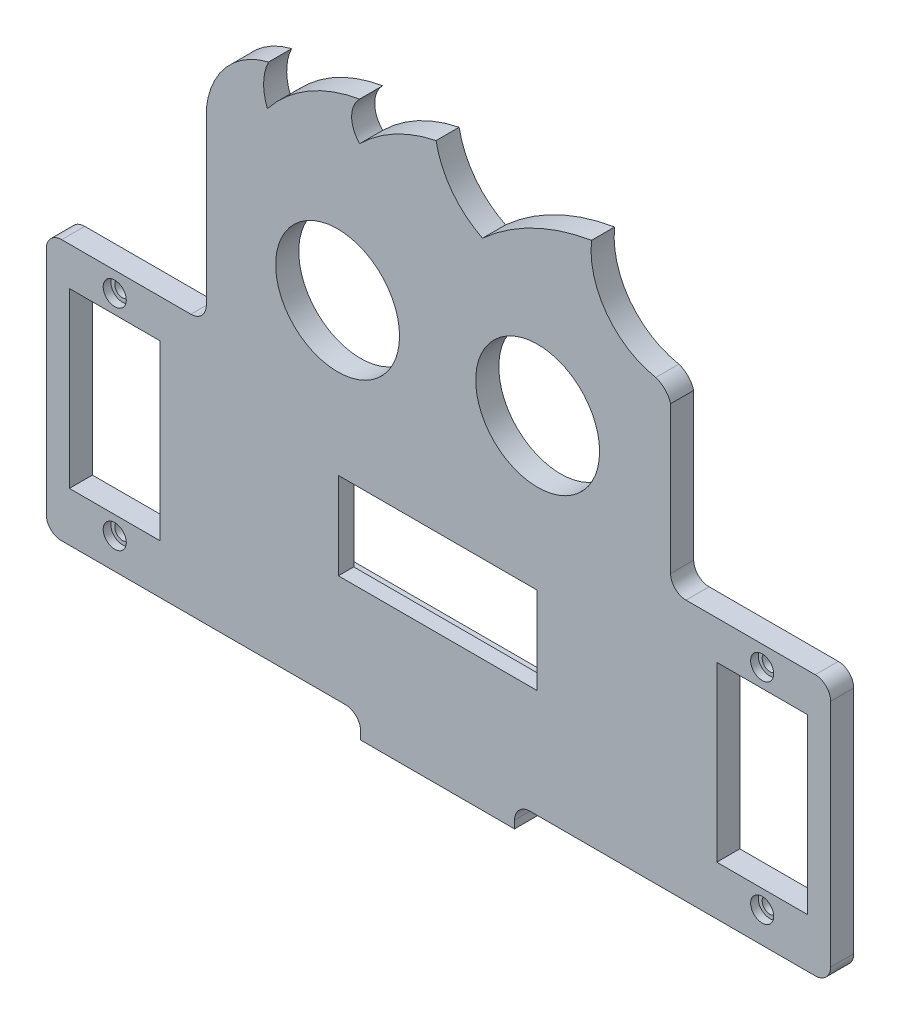
from build123d import *

# Parameters (mm, degrees)
MODEL_R                 = 8.05
MODEL_R_2               = 1
MODEL_W                 = 25.8
MODEL_H                 = 11.3
MODEL_W_2               = 11.8
MODEL_H_2               = 22.5
SALIENTE_EXTRUIR1_DEPTH = 3
CROQUIS2_W              = 38.3
CROQUIS2_H              = 12.1
CORTAR_EXTRUIR1_DEPTH   = 1
CROQUIS3_R              = 1.5
CORTAR_EXTRUIR2_DEPTH   = 1
CROQUIS4_W              = 20
CROQUIS4_H              = 3
SALIENTE_EXTRUIR2_DEPTH = 8
CROQUIS5_R              = 1.5
CORTAR_EXTRUIR3_DEPTH   = 3
CROQUIS6_R              = 2.25
CORTAR_EXTRUIR4_DEPTH   = 1
REDONDEO1_R             = 2


with BuildPart() as part:
    # Model → Saliente-Extruir1 (new body)
    with BuildSketch(Plane.XY):
        with BuildLine():
            Line((50.589823504, -56.021207572), (70.589823504, -56.021207572))
            Line((70.589823504, -56.021207572), (70.589823504, -55.020997464))
            ThreePointArc((70.589823504, -55.020997464), (71.175609941, -53.606783901), (72.589823504, -53.020997464))
            Line((72.589823504, -53.020997464), (88.870799912, -53.020997464))
            Line((88.870799912, -53.020997464), (109.670799912, -53.020997464))
            ThreePointArc((109.670799912, -53.020997464), (111.085013474, -52.435211026), (111.670799912, -51.020997464))
            Line((111.670799912, -51.020997464), (111.670799912, -21.120997464))
            ThreePointArc((111.670799912, -21.120997464), (111.085013474, -19.706783901), (109.670799912, -19.120997464))
            Line((109.670799912, -19.120997464), (92.870799912, -19.120997464))
            ThreePointArc((92.870799912, -19.120997464), (91.456586349, -18.535211026), (90.870799912, -17.120997464))
            Line((90.870799912, -17.120997464), (90.870799912, 1.979002536))
            ThreePointArc((90.870799912, 1.979002536), (90.150187884, 3.212884764), (88.940527152, 3.973455574))
            ThreePointArc((88.940527152, 3.973455574), (82.556801864, 7.967186508), (80.592387516, 15.236499516))
            ThreePointArc((80.592387516, 15.236499516), (73.016137183, 12.831206377), (66.424253692, 8.389126209))
            ThreePointArc((66.424253692, 8.389126209), (62.464845981, 11.66270114), (60.387431279, 16.361376528))
            ThreePointArc((60.387431279, 16.361376528), (55.039384462, 14.426569266), (50.461877073, 11.051438157))
            ThreePointArc((50.461877073, 11.051438157), (49.41482724, 13.546636971), (50.438823204, 16.051385009))
            ThreePointArc((50.438823204, 16.051385009), (43.800023098, 13.634815248), (38.471226177, 8.99613013))
            ThreePointArc((38.471226177, 8.99613013), (37.976525569, 11.673196605), (38.618250464, 14.318872844))
            ThreePointArc((38.618250464, 14.318872844), (33.077419178, 10.94136051), (30.527119253, 4.974420659))
            Line((30.527119253, 4.974420659), (30.527119253, -17.120997464))
            ThreePointArc((30.527119253, -17.120997464), (29.941332816, -18.535211026), (28.527119253, -19.120997464))
            Line((28.527119253, -19.120997464), (11.727119253, -19.120997464))
            ThreePointArc((11.727119253, -19.120997464), (10.312905691, -19.706783901), (9.727119253, -21.120997464))
            Line((9.727119253, -21.120997464), (9.727119253, -51.076893199))
            ThreePointArc((9.727119253, -51.076893199), (10.296410138, -52.451282972), (11.670799912, -53.020573857))
            Line((11.670799912, -53.020573857), (32.527119253, -53.020997464))
            Line((32.527119253, -53.020997464), (48.589823504, -53.020997464))
            ThreePointArc((48.589823504, -53.020997464), (50.004037066, -53.606783901), (50.589823504, -55.020997464))
            Line((50.589823504, -55.020997464), (50.589823504, -56.021207572))
        make_face()
        with Locations((47.589823504, -8.020840193)):
            Circle(MODEL_R, mode=Mode.SUBTRACT)
        with Locations((73.589823504, -8.020840193)):
            Circle(MODEL_R, mode=Mode.SUBTRACT)
        with Locations((102.770799912, -21.720997464)):
            Circle(MODEL_R_2, mode=Mode.SUBTRACT)
        with Locations((102.770799912, -49.020997464)):
            Circle(MODEL_R_2, mode=Mode.SUBTRACT)
        with Locations((18.627119253, -21.720997464)):
            Circle(MODEL_R_2, mode=Mode.SUBTRACT)
        with Locations((18.627119253, -49.020997464)):
            Circle(MODEL_R_2, mode=Mode.SUBTRACT)
        with Locations((60.589823504, -33.326919867)):
            Rectangle(MODEL_W, MODEL_H, mode=Mode.SUBTRACT)
        with Locations((102.770799912, -35.370997464)):
            Rectangle(MODEL_W_2, MODEL_H_2, mode=Mode.SUBTRACT)
        with Locations((18.627119253, -35.370997464)):
            Rectangle(MODEL_W_2, MODEL_H_2, mode=Mode.SUBTRACT)
    extrude(amount=SALIENTE_EXTRUIR1_DEPTH)

    # Croquis2 → Cortar-Extruir1 (cut)
    with BuildSketch(Plane(origin=(0, 0, 0), x_dir=(-1, 0, 0), z_dir=(0, 0, -1))):
        with Locations((-61.789823504, -33.326919867)):
            Rectangle(CROQUIS2_W, CROQUIS2_H)
    extrude(amount=-CORTAR_EXTRUIR1_DEPTH, mode=Mode.SUBTRACT)

    # Croquis3 → Cortar-Extruir2 (cut)
    with BuildSketch(Plane.XY.offset(3)):
        with Locations((18.627119253, -21.720997464)):
            Circle(CROQUIS3_R)
        with Locations((18.627119253, -49.020997464)):
            Circle(CROQUIS3_R)
        with Locations((102.770799912, -49.020997464)):
            Circle(CROQUIS3_R)
        with Locations((102.770799912, -21.720997464)):
            Circle(CROQUIS3_R)
    extrude(amount=-CORTAR_EXTRUIR2_DEPTH, mode=Mode.SUBTRACT)

    # Croquis4 → Saliente-Extruir2 (add)
    with BuildSketch(Plane(origin=(0, 0, 0), x_dir=(-1, 0, 0), z_dir=(0, 0, -1))):
        with Locations((-60.589823504, -54.521207572)):
            Rectangle(CROQUIS4_W, CROQUIS4_H)
    extrude(amount=SALIENTE_EXTRUIR2_DEPTH)

    # Croquis5 → Cortar-Extruir3 (cut)
    with BuildSketch(Plane(origin=(0, -53.021207572, 0), x_dir=(1, 0, 0), z_dir=(0, 1, 0))):
        with Locations((54.589823504, 3.5)):
            Circle(CROQUIS5_R)
        with Locations((66.589823504, 3.5)):
            Circle(CROQUIS5_R)
    extrude(amount=-CORTAR_EXTRUIR3_DEPTH, mode=Mode.SUBTRACT)

    # Croquis6 → Cortar-Extruir4 (cut)
    with BuildSketch(Plane(origin=(0, -53.021207572, 0), x_dir=(1, 0, 0), z_dir=(0, 1, 0))):
        with Locations((66.589823504, 3.5)):
            Circle(CROQUIS6_R)
        with Locations((54.589823504, 3.5)):
            Circle(CROQUIS6_R)
    extrude(amount=-CORTAR_EXTRUIR4_DEPTH, mode=Mode.SUBTRACT)

    # Redondeo1
    redondeo1_edges = [part.edges().sort_by_distance(p)[0] for p in [
        (70.589823504, -54.521207572, -8),
        (50.589823504, -54.521207572, -8),
    ]]
    fillet(redondeo1_edges, radius=REDONDEO1_R)


solid = part.part
